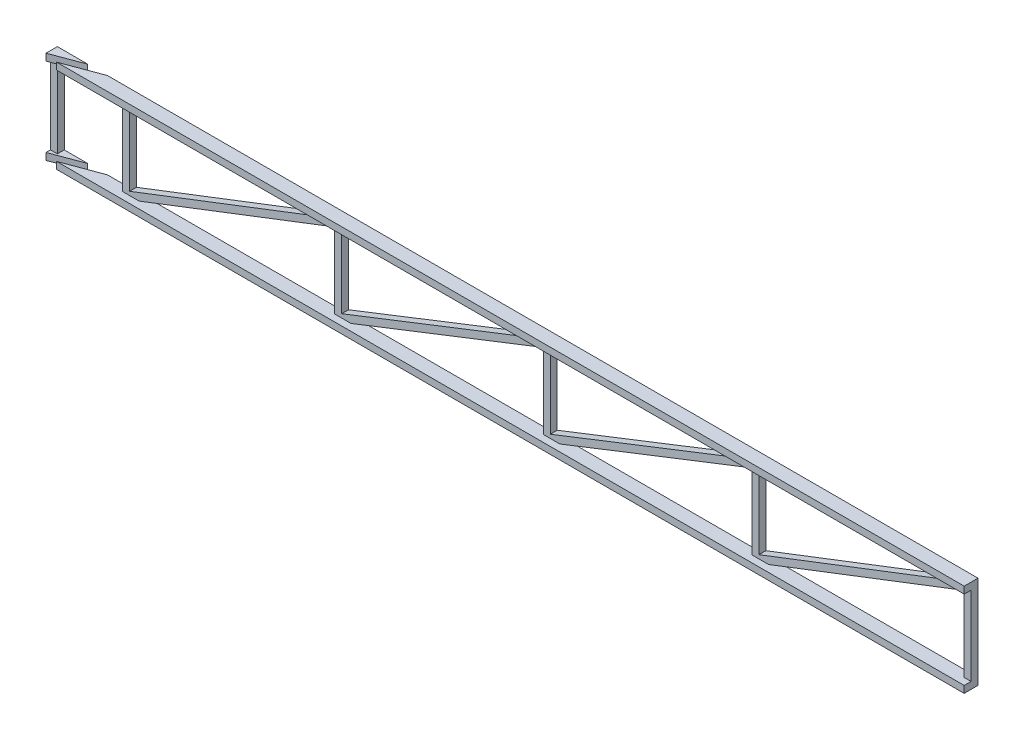
from build123d import *

# Parameters (mm, degrees)
BOSS_EXTRUDE1_DEPTH   = 3.175
BOSS_EXTRUDE1_2_DEPTH = 3.175
SKETCH2_W             = 3.175
SKETCH2_H             = 36.35
BOSS_EXTRUDE2_DEPTH   = 3.175
SKETCH3_W             = 3.175
SKETCH3_H             = 3.175
BOSS_EXTRUDE8_DEPTH   = 423.175
BOSS_EXTRUDE8_2_DEPTH = 423.175
SKETCH4_W             = 3.175
SKETCH4_H             = 36.35
CUT_EXTRUDE1_DEPTH    = 427.326430831
CUT_EXTRUDE7_DEPTH    = 3.175
CUT_EXTRUDE8_DEPTH    = 3.175
SKETCH10_W            = 408.638332101
SKETCH10_H            = 3.175
BOSS_EXTRUDE9_DEPTH   = 3.175
BOSS_EXTRUDE10_DEPTH  = 3.175
BOSS_EXTRUDE11_DEPTH  = 3.175


with BuildPart() as part:
    # Sketch1 → Boss-Extrude1 (new body)
    with BuildSketch(Plane.XY):
        Polygon((15, 45), (405, 45), (405, 48.175), (18.175, 48.175), (-18.175, 48.175), (-18.175, 45), (-15, 45), align=None)
    extrude(amount=BOSS_EXTRUDE1_DEPTH)



with BuildPart() as body_2:
    # Sketch1 → Boss-Extrude1 2 (new body)
    with BuildSketch(Plane.XY):
        Polygon((-18.175, 15), (-15, 15), (15, 15), (405, 15), (405, 11.825), (18.175, 11.825), (-18.175, 11.825), align=None)
    extrude(amount=BOSS_EXTRUDE1_2_DEPTH)


with BuildPart() as part_1:
    add(part.part)

    add(body_2.part)  # Boss-Extrude2 merges body 2
    # Sketch2 → Boss-Extrude2 (add)
    with BuildSketch(Plane.XY.offset(3.175)):
        with Locations((-16.5875, 30)):
            Rectangle(SKETCH2_W, SKETCH2_H)
        Polygon((15, 11.825), (22.589723325, 11.825), (112.5, 46.473699254), (112.5, 12.285600704), (112.5, 11.825), (120.025102002, 11.825), (208.4125, 46.469905429), (208.4125, 11.825), (215.937602002, 11.825), (304.325, 46.469905429), (304.325, 11.825), (311.914723325, 11.825), (401.825, 46.473699254), (401.825, 11.825), (405, 11.825), (405, 48.175), (397.410276675, 48.175), (307.5, 13.526300746), (307.5, 48.175), (299.974897998, 48.175), (211.5875, 13.530094571), (211.5875, 48.175), (204.062397998, 48.175), (115.675, 13.530094571), (115.675, 48.175), (108.085276675, 48.175), (18.175, 13.526300746), (18.175, 48.175), (15, 48.175), align=None)
    extrude(amount=BOSS_EXTRUDE2_DEPTH)

    # Sketch4 → Cut-Extrude1 (cut, through all)
    with BuildSketch(Plane(origin=(405, 0, 0), x_dir=(0, 0, -1), z_dir=(1, 0, 0))):
        with Locations((-1.5875, 30)):
            Rectangle(SKETCH4_W, SKETCH4_H)
    extrude(amount=-CUT_EXTRUDE1_DEPTH, mode=Mode.SUBTRACT)


with BuildPart() as body_2_2:
    # Sketch3 → Boss-Extrude8 (new body)
    with BuildSketch(Plane(origin=(405, 0, 0), x_dir=(0, 0, -1), z_dir=(1, 0, 0))):
        with Locations((-4.7625, 49.7625)):
            Rectangle(SKETCH3_W, SKETCH3_H)
    extrude(amount=-BOSS_EXTRUDE8_DEPTH)

    # Sketch9 → Cut-Extrude8 (cut)
    with BuildSketch(Plane(origin=(0, 51.35, 0), x_dir=(1, 0, 0), z_dir=(0, 1, 0))):
        Polygon((-3.638332101, -6.35), (4.861361865, -3.175), (-4.211973934, -3.175), (-12.711667899, -6.35), align=None)
    extrude(amount=-CUT_EXTRUDE8_DEPTH, mode=Mode.SUBTRACT)


with BuildPart() as body_3:
    # Sketch3 → Boss-Extrude8 2 (new body)
    with BuildSketch(Plane(origin=(405, 0, 0), x_dir=(0, 0, -1), z_dir=(1, 0, 0))):
        with Locations((-4.7625, 10.2375)):
            Rectangle(SKETCH3_W, SKETCH3_H)
    extrude(amount=-BOSS_EXTRUDE8_2_DEPTH)

    # Sketch5 → Cut-Extrude7 (cut)
    with BuildSketch(Plane.XZ.offset(-8.65)):
        Polygon((-4.211973934, 3.175), (4.861361865, 3.175), (-3.638332101, 6.35), (-12.711667899, 6.35), align=None)
    extrude(amount=-CUT_EXTRUDE7_DEPTH, mode=Mode.SUBTRACT)


with BuildPart() as cut_extrude1_piece_1:
    # of the separate pieces the step leaves, piece 1, a body of its own (cut_extrude1_pieces)
    add(part_1.part.solids().sort_by_distance((401.825, 11.825, 3.175))[0])



with BuildPart() as cut_extrude1_piece_2:
    # of the separate pieces the step leaves, piece 2, a body of its own (cut_extrude1_pieces)
    add(part_1.part.solids().sort_by_distance((-15, 48.175, 3.175))[0])


with BuildPart() as cut_extrude7_piece_1:
    # of the separate pieces the step leaves, piece 1, a body of its own (cut_extrude7_pieces)
    add(body_3.part.solids().sort_by_distance((405, 11.825, 3.175))[0])


with BuildPart() as cut_extrude7_piece_2:
    # of the separate pieces the step leaves, piece 2, a body of its own (cut_extrude7_pieces)
    add(body_3.part.solids().sort_by_distance((-12.711667899, 11.825, 6.35))[0])


with BuildPart() as cut_extrude8_piece_1:
    # of the separate pieces the step leaves, piece 1, a body of its own (cut_extrude8_pieces)
    add(body_2_2.part.solids().sort_by_distance((405, 51.35, 6.35))[0])


with BuildPart() as cut_extrude8_piece_2:
    # of the separate pieces the step leaves, piece 2, a body of its own (cut_extrude8_pieces)
    add(body_2_2.part.solids().sort_by_distance((-12.711667899, 51.35, 6.35))[0])


with BuildPart() as cut_extrude1_piece_1_1:
    add(cut_extrude1_piece_1.part)

    add(cut_extrude7_piece_1.part)  # Boss-Extrude9 merges Cut-Extrude7 piece 1

    add(cut_extrude8_piece_1.part)  # Boss-Extrude9 merges Cut-Extrude8 piece 1
    # Sketch10 → Boss-Extrude9 (add)
    with BuildSketch(Plane.XY.offset(6.35)):
        with Locations((200.680833949, 49.7625)):
            Rectangle(SKETCH10_W, SKETCH10_H)
        with Locations((200.680833949, 10.2375)):
            Rectangle(SKETCH10_W, SKETCH10_H)
    extrude(amount=BOSS_EXTRUDE9_DEPTH)


    add(cut_extrude1_piece_2.part)  # Boss-Extrude10 merges Cut-Extrude1 piece 2

    add(cut_extrude8_piece_2.part)  # Boss-Extrude10 merges Cut-Extrude8 piece 2
    # Sketch11 → Boss-Extrude10 (add)
    with BuildSketch(Plane(origin=(0, 51.35, 0), x_dir=(1, 0, 0), z_dir=(0, 1, 0))):
        Polygon((-18.175, -8.390788703), (-12.711667899, -6.35), (-18.175, -6.35), align=None)
        Polygon((405, -6.35), (-3.638332101, -6.35), (-12.138026066, -9.525), (405, -9.525), align=None)
    extrude(amount=-BOSS_EXTRUDE10_DEPTH)


    add(cut_extrude7_piece_2.part)  # Boss-Extrude11 merges Cut-Extrude7 piece 2
    # Sketch12 → Boss-Extrude11 (add)
    with BuildSketch(Plane.XZ.offset(-8.65)):
        Polygon((-3.638332101, 9.525), (-12.138026066, 9.525), (-3.638332101, 6.35), align=None)
        Polygon((-12.711667899, 6.35), (-18.175, 8.390788703), (-18.175, 6.35), align=None)
    extrude(amount=-BOSS_EXTRUDE11_DEPTH)


solid = cut_extrude1_piece_1_1.part
